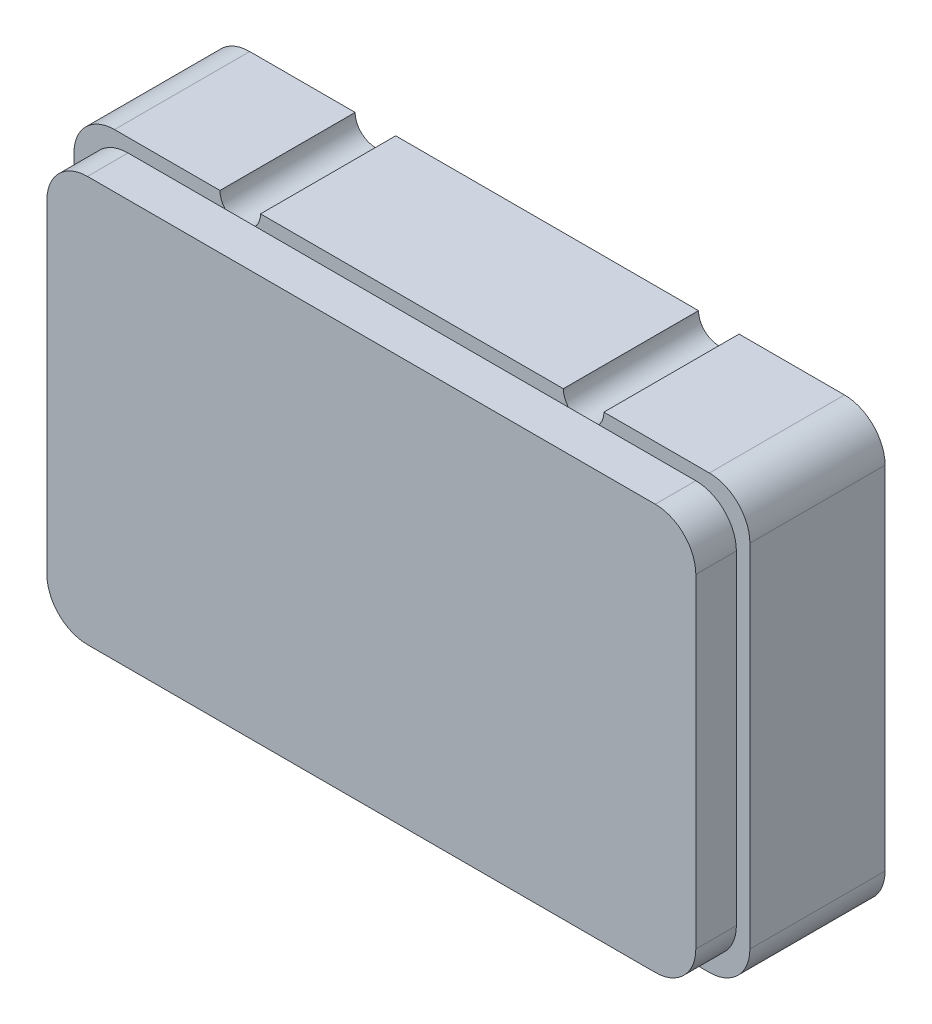
from build123d import *

# Parameters (mm, degrees)
SKETCH1_W            = 5
SKETCH1_H            = 3.2
BOSS_EXTRUDE1_DEPTH  = 1
SKETCH2_W            = 4.8
SKETCH2_H            = 3
BOSS_EXTRUDE2_DEPTH  = 0.3
FILLET1_R            = 0.3
FILLET2_R            = 0.3
CUT_EXTRUDE1_DEPTH   = 1
LPATTERN1_COUNT      = 2
LPATTERN1_PITCH      = 2.54
MIRROR1_COPY_1_DEPTH = 1


with BuildPart() as part:
    # Sketch1 → Boss-Extrude1 (new body)
    with BuildSketch(Plane.XY):
        with Locations((2.5, 1.6)):
            Rectangle(SKETCH1_W, SKETCH1_H)
    extrude(amount=BOSS_EXTRUDE1_DEPTH)

    # Sketch2 → Boss-Extrude2 (add)
    with BuildSketch(Plane.XY.offset(1)):
        with Locations((2.5, 1.6)):
            Rectangle(SKETCH2_W, SKETCH2_H)
    extrude(amount=BOSS_EXTRUDE2_DEPTH)

    # Fillet1
    fillet1_edges = [part.edges().sort_by_distance(p)[0] for p in [
        (0.1, 3.1, 1.15),
        (0.1, 0.1, 1.15),
        (4.9, 0.1, 1.15),
        (4.9, 3.1, 1.15),
    ]]
    fillet(fillet1_edges, radius=FILLET1_R)

    # Fillet2
    fillet2_edges = [part.edges().sort_by_distance(p)[0] for p in [
        (0, 3.2, 0.5),
        (5, 3.2, 0.5),
        (5, 0, 0.5),
        (0, 0, 0.5),
    ]]
    fillet(fillet2_edges, radius=FILLET2_R)

    # Sketch3 → Cut-Extrude1 (cut)
    with BuildSketch(Plane(origin=(0, 0, 0), x_dir=(-1, 0, 0), z_dir=(0, 0, -1))):
        with BuildLine():
            Line((-3.92, 3.2), (-3.62, 3.2))
            ThreePointArc((-3.62, 3.2), (-3.77, 3.05), (-3.92, 3.2))
        make_face()
    cut_extrude1 = extrude(amount=-CUT_EXTRUDE1_DEPTH, mode=Mode.SUBTRACT)

    # LPattern1: Cut-Extrude1 ×2
    with Locations(*[(-i * LPATTERN1_PITCH, 0, 0) for i in range(1, LPATTERN1_COUNT)]):
        add(cut_extrude1, mode=Mode.SUBTRACT)

    # Mirror1: Cut-Extrude1 across plane
    add(cut_extrude1.mirror(Plane.ZX.offset(1.6)), mode=Mode.SUBTRACT)

    # Mirror1 copy 1 sketch → Mirror1 copy 1 (cut)
    with BuildSketch(Plane(origin=(-2.54, 3.2, 0), x_dir=(-1, 0, 0), z_dir=(0, 0, -1))):
        with BuildLine():
            Line((-3.92, -3.2), (-3.62, -3.2))
            ThreePointArc((-3.62, -3.2), (-3.77, -3.05), (-3.92, -3.2))
        make_face()
    extrude(amount=-MIRROR1_COPY_1_DEPTH, mode=Mode.SUBTRACT)


solid = part.part
